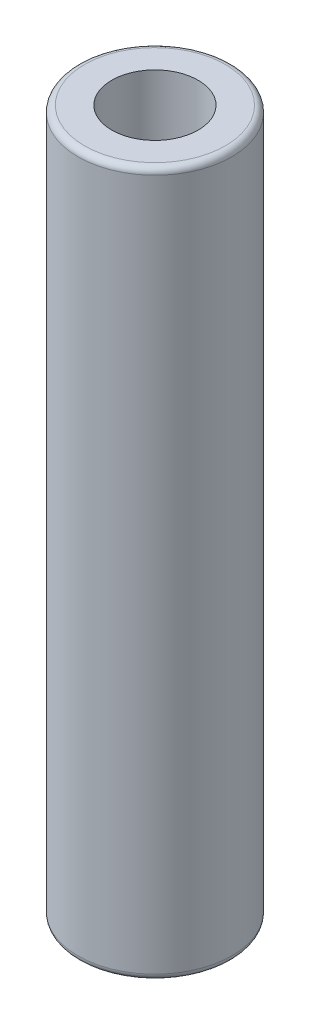
from build123d import *

# Parameters (mm, degrees)
F_1_2_13_TAPPED_HOLE1_D     = 10.71626
F_1_2_13_TAPPED_HOLE1_DEPTH = 19.05
F_1_2_13_TAPPED_HOLE1_TIP   = 3.219489309


with BuildPart() as part:
    # Sketch1 → Revolve1 (revolve)
    with BuildSketch(Plane.XY):
        with BuildLine():
            Line((0, 0), (0, 87.3506))
            Line((0, 87.3506), (8.73125, 87.3506))
            ThreePointArc((8.73125, 87.3506), (9.292516008, 87.118116008), (9.525, 86.55685))
            Line((9.525, 86.55685), (9.525, 0.79375))
            ThreePointArc((9.525, 0.79375), (9.292516008, 0.232483992), (8.73125, 0))
            Line((8.73125, 0), (0, 0))
        make_face()
    revolve(axis=Axis((0, 288.392157732, 0), (0, -1, 0)))

    # 1/2-13 Tapped Hole1
    with Locations(Plane(origin=(0, 87.3506, 0), x_dir=(1, 0, 0), z_dir=(0, 1, 0))):
        with Locations((0, 0)):
            Hole(F_1_2_13_TAPPED_HOLE1_D / 2, depth=F_1_2_13_TAPPED_HOLE1_DEPTH)
            with Locations((0, 0, -(F_1_2_13_TAPPED_HOLE1_DEPTH + F_1_2_13_TAPPED_HOLE1_TIP / 2))):  # 118° drill point
                Cone(0, F_1_2_13_TAPPED_HOLE1_D / 2, F_1_2_13_TAPPED_HOLE1_TIP, mode=Mode.SUBTRACT)


solid = part.part
